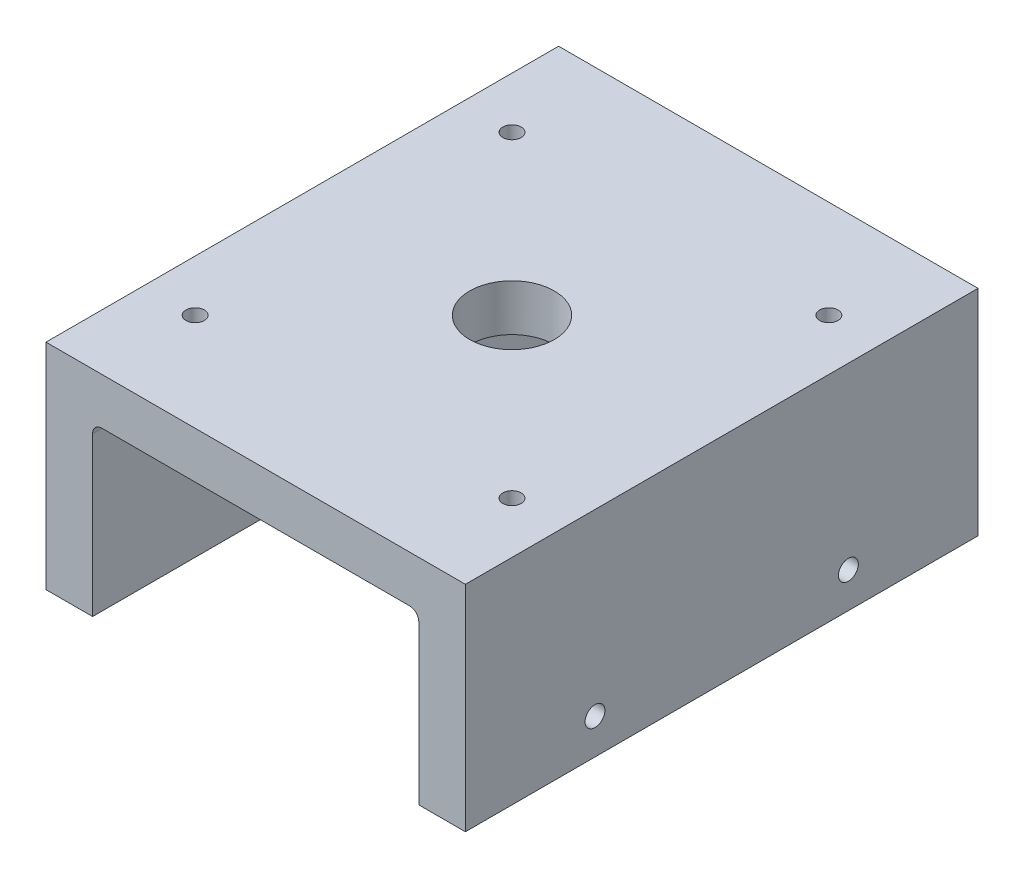
from build123d import *

# Parameters (mm, degrees)
BOSS_EXTRUDE1_DEPTH             = 69.85
TAP_DRILL_FOR_1_2_20_TAP1_D     = 11.50874
TAP_DRILL_FOR_1_2_20_TAP1_DEPTH = 12.7
TAP_DRILL_FOR_1_2_20_TAP1_TIP   = 3.45757432
LPATTERN2_COUNT                 = 2
LPATTERN2_PITCH                 = 43.18
LPATTERN2_COUNT_DIR2            = 2
LPATTERN2_PITCH_DIR2            = 43.18
TAP_DRILL_FOR_8_32_TAP1_D       = 3.4544
TAP_DRILL_FOR_8_32_TAP1_DEPTH   = 4.826
TAP_DRILL_FOR_8_32_TAP1_TIP     = 1.037806461
TAP_DRILL_FOR_8_32_TAP4_D       = 3.4544
TAP_DRILL_FOR_8_32_TAP4_DEPTH   = 4.064
TAP_DRILL_FOR_8_32_TAP4_TIP     = 1.037806461
TAP_DRILL_FOR_6_32_TAP1_D       = 2.7051
TAP_DRILL_FOR_6_32_TAP1_DEPTH   = 5.08
TAP_DRILL_FOR_6_32_TAP1_TIP     = 0.81269403


with BuildPart() as part:
    # Sketch1 → Boss-Extrude1 (new body)
    with BuildSketch(Plane.XY):
        with BuildLine():
            Line((-64.452009828, -5.932047122), (-64.452009828, -35.142047122))
            Line((-64.452009828, -35.142047122), (-58.102009828, -35.142047122))
            Line((-58.102009828, -35.142047122), (-58.102009828, -13.552047122))
            ThreePointArc((-58.102009828, -13.552047122), (-57.73003544, -12.65402151), (-56.832009828, -12.282047122))
            Line((-56.832009828, -12.282047122), (-14.922009828, -12.282047122))
            ThreePointArc((-14.922009828, -12.282047122), (-14.023984216, -12.65402151), (-13.652009828, -13.552047122))
            Line((-13.652009828, -13.552047122), (-13.652009828, -35.142047122))
            Line((-13.652009828, -35.142047122), (-7.302009828, -35.142047122))
            Line((-7.302009828, -35.142047122), (-7.302009828, -5.932047122))
            Line((-7.302009828, -5.932047122), (-64.452009828, -5.932047122))
        make_face()
    extrude(amount=BOSS_EXTRUDE1_DEPTH)

    # Tap Drill for 1/2-20 Tap1
    with Locations(Plane(origin=(0, -5.932047122, 0), x_dir=(-1, 0, 0), z_dir=(0, 1, 0))):
        with Locations((35.877009828, 34.925)):
            Hole(TAP_DRILL_FOR_1_2_20_TAP1_D / 2, depth=TAP_DRILL_FOR_1_2_20_TAP1_DEPTH)
            with Locations((0, 0, -(TAP_DRILL_FOR_1_2_20_TAP1_DEPTH + TAP_DRILL_FOR_1_2_20_TAP1_TIP / 2))):  # 118° drill point
                Cone(0, TAP_DRILL_FOR_1_2_20_TAP1_D / 2, TAP_DRILL_FOR_1_2_20_TAP1_TIP, mode=Mode.SUBTRACT)

    # Sketch10 → Tap Drill for M3x0.5 Tap1 (revolve, cut)
    with BuildSketch(Plane(origin=(-57.467009828, -5.932047122, 13.335), x_dir=(0, 0, 1), z_dir=(1, 0, 0))):
        Polygon((0, 0), (0, 4.053075774), (1.25, 3.302), (1.25, 0), align=None)
    tap_drill_for_m3x0_5_tap1 = revolve(axis=Axis((-57.467009828, 0.417952878, 13.335), (0, -1, 0)), mode=Mode.SUBTRACT)

    # LPattern2: Tap Drill for M3x0.5 Tap1 2 × 2
    with Locations(*[(i * LPATTERN2_PITCH, 0, j * LPATTERN2_PITCH_DIR2) for i in range(LPATTERN2_COUNT) for j in range(LPATTERN2_COUNT_DIR2) if (i, j) != (0, 0)]):
        add(tap_drill_for_m3x0_5_tap1, mode=Mode.SUBTRACT)

    # Tap Drill for #8-32 Tap1
    with Locations(Plane.XZ.offset(12.282047122)):
        with Locations((-52.387009828, 64.135), (-19.367009828, 64.135), (-52.387009828, 5.715), (-19.367009828, 5.715)):
            Hole(TAP_DRILL_FOR_8_32_TAP1_D / 2, depth=TAP_DRILL_FOR_8_32_TAP1_DEPTH)
            with Locations((0, 0, -(TAP_DRILL_FOR_8_32_TAP1_DEPTH + TAP_DRILL_FOR_8_32_TAP1_TIP / 2))):  # 118° drill point
                Cone(0, TAP_DRILL_FOR_8_32_TAP1_D / 2, TAP_DRILL_FOR_8_32_TAP1_TIP, mode=Mode.SUBTRACT)

    # Tap Drill for #8-32 Tap4
    with Locations(Plane.ZY.offset(64.452009828)):
        with Locations((19.05, -16.854047122), (50.8, -16.854047122)):
            Hole(TAP_DRILL_FOR_8_32_TAP4_D / 2, depth=TAP_DRILL_FOR_8_32_TAP4_DEPTH)
            with Locations((0, 0, -(TAP_DRILL_FOR_8_32_TAP4_DEPTH + TAP_DRILL_FOR_8_32_TAP4_TIP / 2))):  # 118° drill point
                Cone(0, TAP_DRILL_FOR_8_32_TAP4_D / 2, TAP_DRILL_FOR_8_32_TAP4_TIP, mode=Mode.SUBTRACT)

    # Tap Drill for #6-32 Tap1
    with Locations(Plane(origin=(-7.302009828, 0, 0), x_dir=(0, 0, -1), z_dir=(1, 0, 0))):
        with Locations((-52.1890625, -30.316047122), (-17.6609375, -30.316047122)):
            Hole(TAP_DRILL_FOR_6_32_TAP1_D / 2, depth=TAP_DRILL_FOR_6_32_TAP1_DEPTH)
            with Locations((0, 0, -(TAP_DRILL_FOR_6_32_TAP1_DEPTH + TAP_DRILL_FOR_6_32_TAP1_TIP / 2))):  # 118° drill point
                Cone(0, TAP_DRILL_FOR_6_32_TAP1_D / 2, TAP_DRILL_FOR_6_32_TAP1_TIP, mode=Mode.SUBTRACT)


solid = part.part
